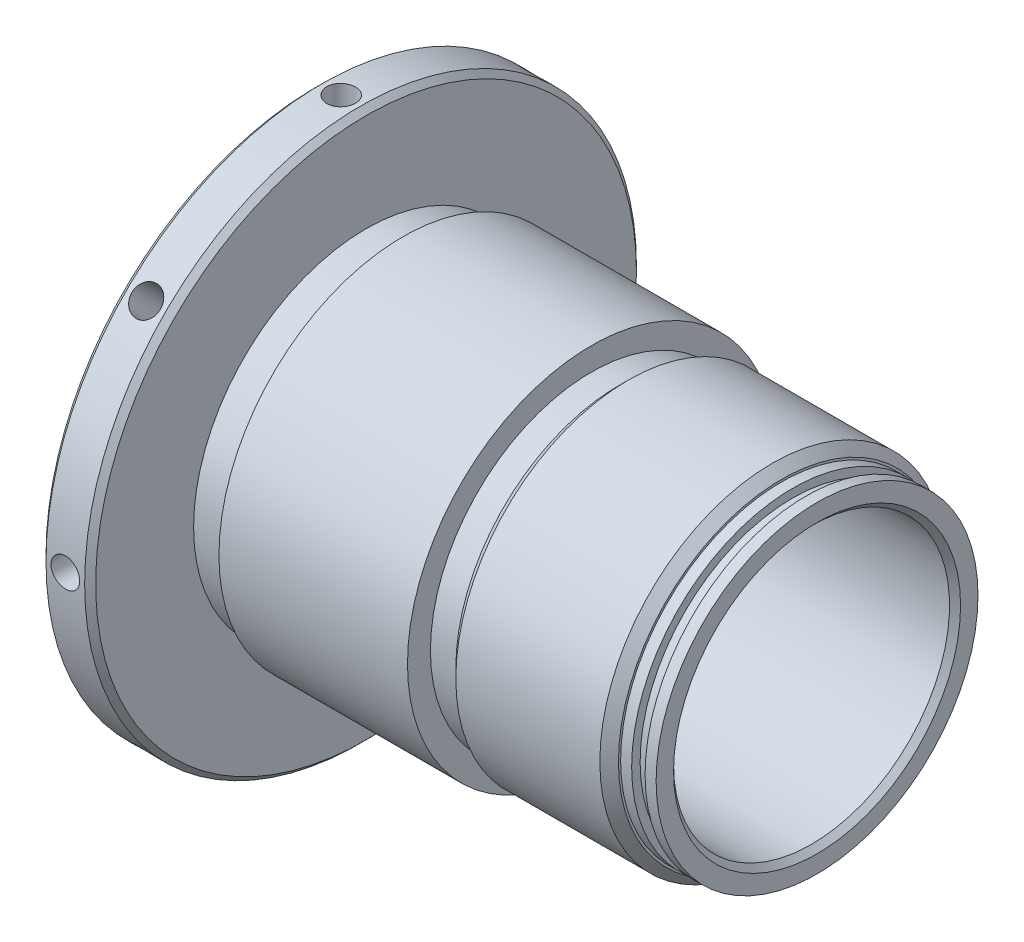
from build123d import *

# Parameters (mm, degrees)
CHAMFER1_SIZE      = 0.762
SKETCH3_W          = 6.858
SKETCH3_H          = 18.7452
SKETCH5_W          = 5.08
SKETCH5_H          = 1.58115
CHAMFER3_SIZE      = 0.762
SKETCH6_R          = 1.9812
CUT_EXTRUDE2_DEPTH = 6.35
CIRPATTERN1_COUNT  = 8
CHAMFER4_SIZE      = 1.2827
SKETCH7_W          = 1.524
SKETCH7_H          = 0.4064
EXTRUDE1_DEPTH     = 0.0254


with BuildPart() as part:
    # Sketch1 → Revolve1 (revolve)
    with BuildSketch(Plane.XY, mode=Mode.PRIVATE) as revolve1_sk:
        Polygon((0, 19.3548), (0, 25.39365), (62.2808, 25.39365), (62.2808, 19.05635), (21.88845, 19.05635), (20.828, 20.1168), (17.78, 20.1168), (17.018, 19.3548), align=None)
    revolve(revolve1_sk.sketch.rotate(Axis((0, 0, 0), (1, 0, 0)), 90), axis=Axis((0, 0, 0), (1, 0, 0)))  # turned: the seam where the file's is

    # Sketch2 → Cut-Revolve1 (revolve, cut)
    with BuildSketch(Plane.XY, mode=Mode.PRIVATE) as cut_revolve1_sk:
        Polygon((31.115, 25.39365), (62.2808, 25.39365), (62.2808, 22.225), (60.7568, 22.225), (60.7568, 21.0566), (58.9026, 21.0566), (58.9026, 22.225), (57.3786, 22.225), (57.3786, 23.8125), (34.925, 23.8125), (34.925, 22.225), (31.115, 22.225), align=None)
    revolve(cut_revolve1_sk.sketch.rotate(Axis((0, 0, 0), (1, 0, 0)), 90), axis=Axis((0, 0, 0), (1, 0, 0)), mode=Mode.SUBTRACT)  # turned: the seam where the file's is

    # Chamfer1
    chamfer1_edges = [part.edges().sort_by_distance(p)[0] for p in [
        (62.2808, 0, -19.05635),
    ]]
    chamfer(chamfer1_edges, length=CHAMFER1_SIZE)

    # Sketch3 → Revolve2 (revolve)
    with BuildSketch(Plane.XY, mode=Mode.PRIVATE) as revolve2_sk:
        with Locations((-3.429, 28.7274)):
            Rectangle(SKETCH3_W, SKETCH3_H)
    revolve(revolve2_sk.sketch.rotate(Axis((0, 0, 0), (-1, 0, 0)), 270), axis=Axis((0, 0, 0), (-1, 0, 0)))  # turned: the seam where the file's is

    # Sketch5 → Cut-Revolve2 (revolve, cut)
    with BuildSketch(Plane.XY, mode=Mode.PRIVATE) as cut_revolve2_sk:
        with Locations((2.54, 24.603075)):
            Rectangle(SKETCH5_W, SKETCH5_H)
    revolve(cut_revolve2_sk.sketch.rotate(Axis((23.353313309, 0, 0), (1, 0, 0)), 90), axis=Axis((23.353313309, 0, 0), (1, 0, 0)), mode=Mode.SUBTRACT)  # turned: the seam where the file's is

    # Chamfer3
    chamfer3_edges = [part.edges().sort_by_distance(p)[0] for p in [
        (0, 0, -38.1),
        (-6.858, 0, -38.1),
    ]]
    chamfer(chamfer3_edges, length=CHAMFER3_SIZE)

    # Sketch6 → Cut-Extrude2 (cut)
    with BuildSketch(Plane(origin=(-3.429, 38.1, 0), x_dir=(0, 0, 1), z_dir=(0, 1, 0))):
        Circle(SKETCH6_R)
    cut_extrude2 = extrude(amount=-CUT_EXTRUDE2_DEPTH, mode=Mode.SUBTRACT)

    # CirPattern1: Cut-Extrude2 ×8 about axis
    cirpattern1_axis = Axis((0, 0, 0), (1, 0, 0))
    for i in range(1, CIRPATTERN1_COUNT):
        add(cut_extrude2.rotate(cirpattern1_axis, i * 360 / CIRPATTERN1_COUNT), mode=Mode.SUBTRACT)

    # Chamfer4
    chamfer4_edges = [part.edges().sort_by_distance(p)[0] for p in [
        (34.925, 0, -23.8125),
        (57.3786, 0, -23.8125),
    ]]
    chamfer(chamfer4_edges, length=CHAMFER4_SIZE)

    # Sketch7 → Extrude1 (cut)
    with BuildSketch(Plane.ZY.offset(6.858)):
        with BuildLine():
            Line((-9.4996, 25.880571028), (-9.1646375, 26.081389778))
            add(Edge.make_bspline(
                [(-9.1646375, 26.081389778), (-9.13348371, 26.02923963), (-9.073794252, 25.929321958), (-8.974223262, 25.794308227), (-8.871050391, 25.679554681), (-8.76351161, 25.58572889), (-8.652263326, 25.511859693), (-8.536579299, 25.459553487), (-8.416849371, 25.426930509), (-8.335366779, 25.422968011), (-8.2946875, 25.420989778)],
                knots=[0, 0, 0, 0, 1.272034388, 2.437168799, 3.508375237, 4.49857839, 5.41946034, 6.295179144, 7.148887113, 8, 8, 8, 8], degree=3))
            add(Edge.make_bspline(
                [(-8.2946875, 25.420989778), (-8.259946467, 25.421957365), (-8.191072287, 25.423875609), (-8.089677592, 25.442307337), (-7.991204251, 25.470623926), (-7.897681832, 25.511177314), (-7.810400786, 25.560241433), (-7.73386228, 25.619503288), (-7.667694601, 25.685852211), (-7.613569219, 25.759872848), (-7.572043227, 25.839479897), (-7.540126584, 25.921191322), (-7.522414572, 26.006290732), (-7.519746458, 26.06358756), (-7.5184, 26.092502278)],
                knots=[0, 0, 0, 0, 1.095163259, 2.171163733, 3.241058638, 4.321873601, 5.38011039, 6.391990106, 7.366004449, 8.327778327, 9.272591725, 10.192022065, 11.087607919, 12, 12, 12, 12], degree=3))
            add(Edge.make_bspline(
                [(-7.5184, 26.092502278), (-7.520069088, 26.12549305), (-7.523462101, 26.192558469), (-7.552140231, 26.291504865), (-7.597254133, 26.389424339), (-7.638873647, 26.449993886), (-7.66048125, 26.481439778)],
                knots=[0, 0, 0, 0, 0.938893495, 1.908633276, 2.914225137, 4, 4, 4, 4], degree=3))
            add(Edge.make_bspline(
                [(-7.66048125, 26.481439778), (-7.678222176, 26.504135074), (-7.715467032, 26.551781007), (-7.7794966, 26.622702573), (-7.854630626, 26.695858009), (-7.938297896, 26.774040753), (-8.033546168, 26.853614572), (-8.137392197, 26.938374019), (-8.252487304, 27.025095759), (-8.333206483, 27.083255374), (-8.37485625, 27.113264778)],
                knots=[0, 0, 0, 0, 0.722233717, 1.516239348, 2.393582979, 3.351407094, 4.387010283, 5.505090956, 6.712668013, 8, 8, 8, 8], degree=3))
            add(Edge.make_bspline(
                [(-8.37485625, 27.113264778), (-8.416545222, 27.142958537), (-8.496251362, 27.199730742), (-8.60771773, 27.283987538), (-8.707394124, 27.361020974), (-8.794837518, 27.431556236), (-8.87000945, 27.49560289), (-8.933502281, 27.552545906), (-8.983698595, 27.603925284), (-9.01161153, 27.637256247), (-9.02414375, 27.652221028)],
                knots=[0, 0, 0, 0, 1.452282411, 2.77665338, 3.964542531, 5.026858415, 5.96415736, 6.766646006, 7.446254459, 8, 8, 8, 8], degree=3))
            add(Edge.make_bspline(
                [(-9.02414375, 27.652221028), (-9.041660439, 27.675543756), (-9.07610936, 27.721411031), (-9.121581869, 27.793102007), (-9.160231303, 27.866489352), (-9.190529321, 27.94177027), (-9.216042897, 28.017887894), (-9.233203406, 28.095835373), (-9.243948753, 28.175262947), (-9.245049152, 28.228714025), (-9.2456, 28.255471028)],
                knots=[0, 0, 0, 0, 1.068054152, 2.10047183, 3.106115577, 4.101338837, 5.06977816, 6.043150881, 7.020423561, 8, 8, 8, 8], degree=3))
            add(Edge.make_bspline(
                [(-9.2456, 28.255471028), (-9.244122354, 28.297392965), (-9.241198646, 28.380340787), (-9.216472685, 28.501511919), (-9.177445429, 28.617198621), (-9.122770097, 28.726255568), (-9.052287658, 28.825843112), (-8.970723382, 28.917106792), (-8.873574972, 28.993828572), (-8.766983442, 29.060863389), (-8.650311851, 29.113332274), (-8.528053807, 29.152912099), (-8.400014996, 29.175338442), (-8.313291493, 29.178556777), (-8.2692875, 29.180189778)],
                knots=[0, 0, 0, 0, 1.005424448, 1.989358655, 2.955360095, 3.929531133, 4.905563448, 5.876582895, 6.856512386, 7.866279853, 8.892233794, 9.918561126, 10.94386622, 12, 12, 12, 12], degree=3))
            add(Edge.make_bspline(
                [(-8.2692875, 29.180189778), (-8.222594465, 29.178579287), (-8.129736921, 29.175376535), (-7.99314822, 29.147529318), (-7.861641014, 29.101451506), (-7.755852559, 29.049160666), (-7.673057915, 28.996934632), (-7.609916807, 28.949363388), (-7.545932594, 28.894597237), (-7.48058916, 28.832490301), (-7.414993711, 28.76247271), (-7.348172418, 28.685023992), (-7.27996902, 28.60061745), (-7.236092958, 28.540361232), (-7.2136, 28.509471028)],
                knots=[0, 0, 0, 0, 1.286793592, 2.559021753, 3.825965368, 5.121522368, 5.803751409, 6.523245864, 7.299691795, 8.125521123, 9.008227632, 9.944561021, 10.946284179, 12, 12, 12, 12], degree=3))
            Line((-7.2136, 28.509471028), (-7.53506875, 28.265789778))
            add(Edge.make_bspline(
                [(-7.53506875, 28.265789778), (-7.554479905, 28.2907967), (-7.591861251, 28.338954185), (-7.64861356, 28.406395722), (-7.702104429, 28.468001396), (-7.754804801, 28.521510923), (-7.803931352, 28.569854618), (-7.851612657, 28.611244441), (-7.897162541, 28.646085932), (-7.95457988, 28.683268596), (-8.026715619, 28.720126279), (-8.117267255, 28.751314983), (-8.211896471, 28.770057205), (-8.27634732, 28.772535276), (-8.308975, 28.773789778)],
                knots=[0, 0, 0, 0, 1.181633172, 2.275549214, 3.290209073, 4.226197932, 5.078386478, 5.862611352, 6.581680152, 7.217281963, 8.414376989, 9.595101626, 10.782541182, 12, 12, 12, 12], degree=3))
            add(Edge.make_bspline(
                [(-8.308975, 28.773789778), (-8.349908316, 28.772417995), (-8.428844359, 28.769772641), (-8.540912619, 28.740881101), (-8.641777124, 28.695390643), (-8.728443377, 28.631635652), (-8.800600919, 28.556099863), (-8.852797568, 28.469177424), (-8.884213925, 28.373194055), (-8.888047581, 28.306238941), (-8.89, 28.272139778)],
                knots=[0, 0, 0, 0, 1.14458467, 2.207223713, 3.21896685, 4.227309161, 5.202851033, 6.127160689, 7.046193047, 8, 8, 8, 8], degree=3))
            add(Edge.make_bspline(
                [(-8.89, 28.272139778), (-8.889554936, 28.250910961), (-8.888664079, 28.208418615), (-8.876239354, 28.145641268), (-8.860277302, 28.08302251), (-8.83498289, 28.02084387), (-8.800062481, 27.958017913), (-8.754205993, 27.893462789), (-8.696453093, 27.826609506), (-8.652213449, 27.78312797), (-8.62885625, 27.760171028)],
                knots=[0, 0, 0, 0, 0.858281714, 1.717966888, 2.583508476, 3.4729293, 4.427298488, 5.488583878, 6.674047936, 8, 8, 8, 8], degree=3))
            add(Edge.make_bspline(
                [(-8.62885625, 27.760171028), (-8.620182701, 27.752430734), (-8.599576333, 27.734041565), (-8.561904183, 27.703936065), (-8.512155913, 27.666799577), (-8.451630591, 27.620850097), (-8.379212227, 27.567548501), (-8.294892858, 27.507576318), (-8.199612384, 27.438986654), (-8.13200035, 27.391033077), (-8.09625, 27.365677278)],
                knots=[0, 0, 0, 0, 0.420754252, 0.999615792, 1.744751191, 2.668019286, 3.750313428, 4.999500688, 6.413464383, 8, 8, 8, 8], degree=3))
            add(Edge.make_bspline(
                [(-8.09625, 27.365677278), (-8.053245605, 27.3343841), (-7.969973554, 27.273789198), (-7.851489213, 27.182749458), (-7.744058577, 27.093711196), (-7.647304463, 27.007243015), (-7.560271017, 26.924000811), (-7.48392381, 26.842983112), (-7.417484913, 26.764770348), (-7.345958817, 26.66449607), (-7.272871987, 26.541343451), (-7.210105865, 26.390457253), (-7.17052902, 26.238984527), (-7.165353542, 26.137177071), (-7.1628, 26.086946028)],
                knots=[0, 0, 0, 0, 1.163667725, 2.253281268, 3.268753668, 4.215851969, 5.092017293, 5.902905408, 6.650798638, 7.335211899, 8.59617414, 9.77448103, 10.901945474, 12, 12, 12, 12], degree=3))
            add(Edge.make_bspline(
                [(-7.1628, 26.086946028), (-7.163543955, 26.051422133), (-7.165017419, 25.981064192), (-7.181954883, 25.877753016), (-7.20677045, 25.777412742), (-7.244172374, 25.681283659), (-7.289822798, 25.587607131), (-7.347748838, 25.498840427), (-7.414891915, 25.41301892), (-7.491913912, 25.332431072), (-7.576195182, 25.25845171), (-7.665274116, 25.192642969), (-7.759296517, 25.137771288), (-7.857752326, 25.092995215), (-7.96066416, 25.057974938), (-8.067997407, 25.032601008), (-8.179928993, 25.017027972), (-8.256007618, 25.015411582), (-8.2946875, 25.014589778)],
                knots=[0, 0, 0, 0, 0.983748083, 1.948392443, 2.894712957, 3.844097841, 4.80183111, 5.778335162, 6.776009319, 7.81870978, 8.863265674, 9.881300176, 10.883814829, 11.87499822, 12.874611388, 13.892143829, 14.928324115, 16, 16, 16, 16], degree=3))
            add(Edge.make_bspline(
                [(-8.2946875, 25.014589778), (-8.324615329, 25.015168494), (-8.384094078, 25.016318638), (-8.472070093, 25.026486474), (-8.558268809, 25.040872367), (-8.64160859, 25.06371172), (-8.723163172, 25.091422455), (-8.802577859, 25.125542492), (-8.879891136, 25.166431292), (-8.955536277, 25.213181979), (-9.029320891, 25.267588838), (-9.100552919, 25.330957233), (-9.171569526, 25.40153947), (-9.240274595, 25.481252275), (-9.308057837, 25.568807823), (-9.373582811, 25.665025292), (-9.438205839, 25.769380591), (-9.478753042, 25.842815281), (-9.4996, 25.880571028)],
                knots=[0, 0, 0, 0, 0.915332311, 1.819136955, 2.706846663, 3.586547465, 4.459518054, 5.340707479, 6.227863349, 7.133153174, 8.059268498, 9.028702269, 10.047606654, 11.120612155, 12.245963614, 13.433783089, 14.680604001, 16, 16, 16, 16], degree=3))
        make_face()
        Polygon((-6.8072, 28.672189778), (-6.8072, 29.078589778), (-4.7244, 29.078589778), (-4.7244, 28.672189778), (-5.588, 28.672189778), (-5.588, 25.116189778), (-5.9436, 25.116189778), (-5.9436, 28.672189778), align=None)
        with BuildLine():
            Line((-0.4064, 28.402314778), (-0.7112, 28.113389778))
            add(Edge.make_bspline(
                [(-0.7112, 28.113389778), (-0.766355349, 28.165275553), (-0.875350837, 28.267809856), (-1.05304777, 28.400845733), (-1.238446919, 28.514811263), (-1.430580862, 28.607538483), (-1.62469154, 28.681525277), (-1.818202449, 28.734200449), (-2.009128657, 28.767793153), (-2.136114767, 28.771810312), (-2.1986875, 28.773789778)],
                knots=[0, 0, 0, 0, 1.08915593, 2.152340314, 3.188132944, 4.216796309, 5.218260357, 6.173443236, 7.099959455, 8, 8, 8, 8], degree=3))
            add(Edge.make_bspline(
                [(-2.1986875, 28.773789778), (-2.237082816, 28.773321529), (-2.313773869, 28.772386245), (-2.427689409, 28.760448988), (-2.540410221, 28.743280629), (-2.651723519, 28.718439916), (-2.761845731, 28.686956882), (-2.870393859, 28.647575763), (-2.977570388, 28.601662591), (-3.082365771, 28.548608915), (-3.183962277, 28.490327846), (-3.279916701, 28.425742378), (-3.370840648, 28.35692252), (-3.455025147, 28.282145263), (-3.532954446, 28.202087954), (-3.606483425, 28.118239827), (-3.673026042, 28.028310081), (-3.733131308, 27.933953307), (-3.786750073, 27.836826744), (-3.834082247, 27.73786525), (-3.873816162, 27.637397064), (-3.905254359, 27.535296118), (-3.931191837, 27.432352298), (-3.94943881, 27.327852805), (-3.959726018, 27.221685748), (-3.961505453, 27.150592074), (-3.9624, 27.114852278)],
                knots=[0, 0, 0, 0, 1.02818874, 2.053710826, 3.065248034, 4.081641283, 5.106893873, 6.131558223, 7.173050175, 8.228653731, 9.27666206, 10.308777013, 11.325269123, 12.329503258, 13.32196095, 14.316845687, 15.314881793, 16.315733098, 17.311955233, 18.285320748, 19.252783886, 20.203351036, 21.145449891, 22.095197417, 23.042428769, 24, 24, 24, 24], degree=3))
            add(Edge.make_bspline(
                [(-3.9624, 27.114852278), (-3.961544441, 27.078318025), (-3.959835658, 27.005349281), (-3.948899072, 26.896446598), (-3.928602255, 26.789161332), (-3.901468069, 26.683140943), (-3.86752636, 26.578203857), (-3.825216231, 26.474805017), (-3.775102512, 26.372948252), (-3.717096879, 26.273551316), (-3.653487676, 26.176729479), (-3.582228915, 26.085526894), (-3.506535093, 25.998729076), (-3.423648591, 25.918263188), (-3.336227244, 25.841976917), (-3.241659161, 25.771972039), (-3.141803896, 25.706900121), (-3.036509102, 25.647581273), (-2.926917289, 25.594588661), (-2.814547301, 25.547465654), (-2.699040154, 25.508657526), (-2.581002873, 25.4770284), (-2.460576173, 25.451102646), (-2.337148768, 25.434423795), (-2.211628191, 25.422320552), (-2.127015518, 25.421435612), (-2.0843875, 25.420989778)],
                knots=[0, 0, 0, 0, 0.93586088, 1.869166235, 2.799637598, 3.729985548, 4.670839027, 5.622275134, 6.589130586, 7.576015415, 8.568469353, 9.55398029, 10.53834874, 11.515998671, 12.510579167, 13.508179873, 14.527009472, 15.561807829, 16.601455013, 17.643573243, 18.680854198, 19.719860599, 20.772568776, 21.833555941, 22.908541556, 24, 24, 24, 24], degree=3))
            add(Edge.make_bspline(
                [(-2.0843875, 25.420989778), (-2.033014025, 25.422063675), (-1.93213386, 25.424172446), (-1.783842237, 25.440588431), (-1.641418783, 25.466227189), (-1.505263696, 25.503774775), (-1.375218837, 25.551667369), (-1.250807468, 25.609399975), (-1.133009099, 25.679186963), (-1.021469607, 25.757952532), (-0.918722101, 25.845708181), (-0.826053877, 25.940403263), (-0.744942996, 26.041578128), (-0.674180533, 26.148636873), (-0.615640426, 26.262465649), (-0.567590332, 26.382506628), (-0.530758928, 26.508813802), (-0.51563957, 26.596090339), (-0.508, 26.640189778)],
                knots=[0, 0, 0, 0, 1.13008108, 2.219097802, 3.278683437, 4.311054135, 5.322181354, 6.324827112, 7.324222904, 8.330512327, 9.32562643, 10.293043162, 11.24128371, 12.174520618, 13.111833804, 14.052305215, 15.015860969, 16, 16, 16, 16], degree=3))
            Line((-0.508, 26.640189778), (-1.8288, 26.640189778))
            Line((-1.8288, 26.640189778), (-1.8288, 27.046589778))
            Line((-1.8288, 27.046589778), (-0.1524, 27.046589778))
            add(Edge.make_bspline(
                [(-0.1524, 27.046589778), (-0.154331215, 26.970842854), (-0.158110953, 26.822592441), (-0.184623842, 26.606392269), (-0.227436455, 26.402190899), (-0.285921832, 26.209773277), (-0.361632293, 26.029412083), (-0.453755294, 25.860924194), (-0.563765241, 25.705398091), (-0.687743576, 25.561564099), (-0.826880374, 25.433262479), (-0.977416048, 25.320497174), (-1.139599309, 25.225509824), (-1.313276743, 25.148230953), (-1.497879789, 25.087918702), (-1.693835617, 25.045156961), (-1.90087849, 25.019537256), (-2.042773932, 25.016263884), (-2.11534375, 25.014589778)],
                knots=[0, 0, 0, 0, 1.140356446, 2.231883559, 3.274166699, 4.278491846, 5.25512956, 6.21435461, 7.1637429, 8.11826594, 9.068280886, 10.0076534, 10.945064095, 11.891975133, 12.864533718, 13.863980011, 14.907571808, 16, 16, 16, 16], degree=3))
            add(Edge.make_bspline(
                [(-2.11534375, 25.014589778), (-2.160073739, 25.015234088), (-2.248295693, 25.016504876), (-2.378591776, 25.025536145), (-2.505295313, 25.039439161), (-2.628387846, 25.06043436), (-2.748322156, 25.086149944), (-2.864499254, 25.119079434), (-2.9773617, 25.15719625), (-3.087083936, 25.200551329), (-3.192670061, 25.250785115), (-3.294590367, 25.306609263), (-3.393408237, 25.367735918), (-3.48845055, 25.435222208), (-3.580212513, 25.508563356), (-3.668102444, 25.587906362), (-3.752612373, 25.673008661), (-3.805550562, 25.7334398), (-3.832225, 25.763889778)],
                knots=[0, 0, 0, 0, 1.107784379, 2.184907829, 3.233506516, 4.263428166, 5.276301166, 6.270063455, 7.25232949, 8.225834625, 9.190232166, 10.146266622, 11.1027726, 12.066435141, 13.031522626, 14.010570082, 14.99756817, 16, 16, 16, 16], degree=3))
            add(Edge.make_bspline(
                [(-3.832225, 25.763889778), (-3.870927382, 25.812197834), (-3.947689726, 25.908012082), (-4.046498574, 26.061526716), (-4.130729465, 26.220477668), (-4.199072739, 26.385307426), (-4.25243844, 26.555861817), (-4.290710982, 26.731922899), (-4.313135097, 26.913717393), (-4.316365627, 27.036738892), (-4.318, 27.098977278)],
                knots=[0, 0, 0, 0, 1.023165419, 2.029347347, 3.013907458, 3.994755782, 4.975994455, 5.96558838, 6.970761222, 8, 8, 8, 8], degree=3))
            add(Edge.make_bspline(
                [(-4.318, 27.098977278), (-4.317397446, 27.145582181), (-4.316199995, 27.238199667), (-4.301680045, 27.375703219), (-4.280847537, 27.510765237), (-4.25022718, 27.643275316), (-4.211626311, 27.773321954), (-4.163450902, 27.900965534), (-4.107360417, 28.026281383), (-4.042167055, 28.14840693), (-3.969616123, 28.265721609), (-3.890877325, 28.377753151), (-3.804832563, 28.482461343), (-3.712886996, 28.581172254), (-3.613943615, 28.672645783), (-3.508929346, 28.757728825), (-3.39776326, 28.836535511), (-3.280095626, 28.90782456), (-3.15768273, 28.971861043), (-3.030818001, 29.028001698), (-2.899540167, 29.074399495), (-2.764832744, 29.113767388), (-2.625676086, 29.142879866), (-2.483080023, 29.163992377), (-2.336301279, 29.178438834), (-2.237087278, 29.179600673), (-2.18678125, 29.180189778)],
                knots=[0, 0, 0, 0, 1.008945113, 2.00506715, 2.99143336, 3.967273523, 4.948097931, 5.927297278, 6.919902385, 7.919676788, 8.923139349, 9.905703106, 10.883022732, 11.856032218, 12.825136022, 13.798837087, 14.781400844, 15.773989409, 16.776158564, 17.77167057, 18.775803737, 19.789618931, 20.80898985, 21.851988756, 22.910860228, 24, 24, 24, 24], degree=3))
            add(Edge.make_bspline(
                [(-2.18678125, 29.180189778), (-2.145755417, 29.179533727), (-2.06440601, 29.178232855), (-1.943353861, 29.169215964), (-1.824172777, 29.154924287), (-1.706686044, 29.135421596), (-1.591293749, 29.108858017), (-1.477667168, 29.07707019), (-1.365641588, 29.04005931), (-1.255568098, 28.995919481), (-1.146706574, 28.94581932), (-1.038451722, 28.889424832), (-0.931173426, 28.825771702), (-0.824685645, 28.754670922), (-0.718316876, 28.677343647), (-0.613749545, 28.591578264), (-0.508459583, 28.500756936), (-0.440757095, 28.435454112), (-0.4064, 28.402314778)],
                knots=[0, 0, 0, 0, 0.985871117, 1.954866573, 2.915460327, 3.869826059, 4.81536089, 5.759505086, 6.70452669, 7.649098992, 8.607881297, 9.583363685, 10.581137262, 11.603961102, 12.659522466, 13.73993555, 14.853081303, 16, 16, 16, 16], degree=3))
        make_face()
        Polygon((2.67096875, 29.078589778), (3.4036, 29.078589778), (3.4036, 25.116189778), (3.048, 25.116189778), (3.048, 28.672189778), (2.4384, 28.672189778), align=None)
        with Locations((5.6388, 26.640189778)):
            Rectangle(SKETCH7_W, SKETCH7_H)
        with BuildLine():
            Line((7.2136, 27.859389778), (6.858, 27.859389778))
            add(Edge.make_bspline(
                [(6.858, 27.859389778), (6.860317611, 27.906565985), (6.864869338, 27.999218801), (6.886185113, 28.1343071), (6.916685265, 28.263430167), (6.959809144, 28.385551238), (7.013365257, 28.501750098), (7.077590132, 28.611565201), (7.15366125, 28.714577626), (7.239935982, 28.809832412), (7.333639541, 28.897217564), (7.43474407, 28.972678917), (7.540987367, 29.036436957), (7.652047098, 29.089738303), (7.76917628, 29.129747048), (7.891312004, 29.15943294), (8.018990876, 29.177293567), (8.105982562, 29.17921339), (8.150225, 29.180189778)],
                knots=[0, 0, 0, 0, 1.10065271, 2.161652631, 3.183658789, 4.190468796, 5.17591951, 6.163126047, 7.15150782, 8.156236427, 9.156009102, 10.134482811, 11.092018607, 12.041330605, 13.001268258, 13.972401359, 14.968799086, 16, 16, 16, 16], degree=3))
            add(Edge.make_bspline(
                [(8.150225, 29.180189778), (8.193673366, 29.179172623), (8.279047853, 29.177173949), (8.403650632, 29.160009931), (8.522270504, 29.133127207), (8.634675603, 29.095410349), (8.739969097, 29.044709259), (8.838941975, 28.983804297), (8.932772524, 28.913364337), (9.01723593, 28.830432648), (9.094794905, 28.741898611), (9.161705413, 28.647380763), (9.219005298, 28.549759357), (9.266766573, 28.448289989), (9.301925672, 28.342017257), (9.328618898, 28.232488367), (9.343707053, 28.118569581), (9.346022706, 28.041465176), (9.3472, 28.002264778)],
                knots=[0, 0, 0, 0, 1.111607364, 2.184268762, 3.212621178, 4.221274766, 5.211760367, 6.196651075, 7.1921475, 8.207485113, 9.220403448, 10.201281604, 11.166441695, 12.114753415, 13.065576456, 14.026450734, 14.996634279, 16, 16, 16, 16], degree=3))
            add(Edge.make_bspline(
                [(9.3472, 28.002264778), (9.345283033, 27.947076658), (9.341482739, 27.837668892), (9.308974783, 27.676891837), (9.258203407, 27.521120361), (9.197072228, 27.39575308), (9.135403196, 27.294730567), (9.079830527, 27.211555596), (9.014773794, 27.121999166), (8.939286114, 27.026361165), (8.854929027, 26.923892476), (8.76093845, 26.814655001), (8.656644139, 26.69977736), (8.583443327, 26.621315499), (8.5455125, 26.580658528)],
                knots=[0, 0, 0, 0, 1.184426356, 2.348067706, 3.509069118, 4.696110526, 5.333549288, 6.050745305, 6.844228056, 7.710549037, 8.667450064, 9.695053472, 10.805634456, 12, 12, 12, 12], degree=3))
            Line((8.5455125, 26.580658528), (7.55411875, 25.522589778))
            Line((7.55411875, 25.522589778), (9.398, 25.522589778))
            Line((9.398, 25.522589778), (9.398, 25.116189778))
            Line((9.398, 25.116189778), (6.7056, 25.116189778))
            Line((6.7056, 25.116189778), (8.2423, 26.756077278))
            add(Edge.make_bspline(
                [(8.2423, 26.756077278), (8.279713985, 26.795133304), (8.351578593, 26.870151936), (8.45322273, 26.979676023), (8.544515281, 27.081282761), (8.6260472, 27.174780172), (8.696049795, 27.261535864), (8.758171433, 27.338740063), (8.807945506, 27.409785272), (8.861964787, 27.49213596), (8.914284296, 27.592681653), (8.959243221, 27.715554194), (8.986657197, 27.842042212), (8.989945803, 27.927519147), (8.9916, 27.970514778)],
                knots=[0, 0, 0, 0, 1.329631726, 2.553950428, 3.673215718, 4.687767853, 5.603093632, 6.413772471, 7.123043292, 7.734684054, 8.834405432, 9.900288307, 10.943827018, 12, 12, 12, 12], degree=3))
            add(Edge.make_bspline(
                [(8.9916, 27.970514778), (8.990880267, 27.99755125), (8.989461812, 28.050834946), (8.976943234, 28.128957351), (8.958025032, 28.204316328), (8.930916263, 28.277143676), (8.895133821, 28.346707177), (8.851577558, 28.413091506), (8.801322933, 28.477269893), (8.743187427, 28.537445501), (8.67932314, 28.59255819), (8.611855639, 28.641379583), (8.540475715, 28.682179975), (8.465484326, 28.71562659), (8.387090541, 28.74186377), (8.305142737, 28.760043917), (8.219867342, 28.771458442), (8.161638747, 28.77300284), (8.13196875, 28.773789778)],
                knots=[0, 0, 0, 0, 0.991446411, 1.95395049, 2.89581595, 3.838931463, 4.798493298, 5.75982156, 6.748411868, 7.785213223, 8.824556874, 9.840280684, 10.836137867, 11.835679398, 12.848801643, 13.863922112, 14.911575587, 16, 16, 16, 16], degree=3))
            add(Edge.make_bspline(
                [(8.13196875, 28.773789778), (8.100981839, 28.77298028), (8.040128663, 28.771390559), (7.950783298, 28.760270181), (7.865551194, 28.741085553), (7.784217949, 28.714846909), (7.706645947, 28.681496465), (7.633212437, 28.639957216), (7.564082267, 28.590389298), (7.499125486, 28.534190515), (7.43927742, 28.471621274), (7.386694248, 28.401871755), (7.340748506, 28.326215483), (7.300661207, 28.244856599), (7.268106479, 28.157056857), (7.243230362, 28.063127933), (7.223546464, 27.96347767), (7.216970555, 27.894662007), (7.2136, 27.859389778)],
                knots=[0, 0, 0, 0, 1.031018746, 2.02475058, 2.990194455, 3.934040569, 4.864654155, 5.795059489, 6.735614925, 7.690564532, 8.649604399, 9.611025574, 10.590972636, 11.591080095, 12.624614302, 13.701020113, 14.821632451, 16, 16, 16, 16], degree=3))
        make_face()
    extrude(amount=-EXTRUDE1_DEPTH, mode=Mode.SUBTRACT)


solid = part.part
